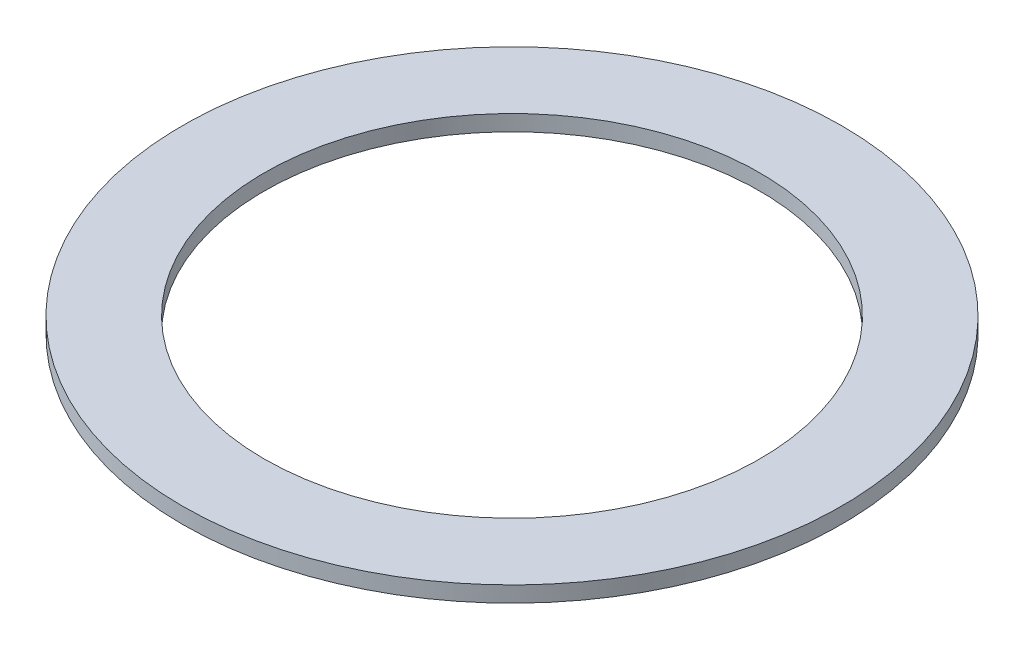
from build123d import *

# Parameters (mm, degrees)
SKETCH1_R           = 3.175
SKETCH1_R_2         = 2.3876
BOSS_EXTRUDE1_DEPTH = 0.1524


with BuildPart() as part:
    # Sketch1 → Boss-Extrude1 (new body)
    with BuildSketch(Plane(origin=(0, 0, 0), x_dir=(1, 0, 0), z_dir=(0, 1, 0))):
        Circle(SKETCH1_R)
        Circle(SKETCH1_R_2, mode=Mode.SUBTRACT)
    extrude(amount=BOSS_EXTRUDE1_DEPTH)


solid = part.part
